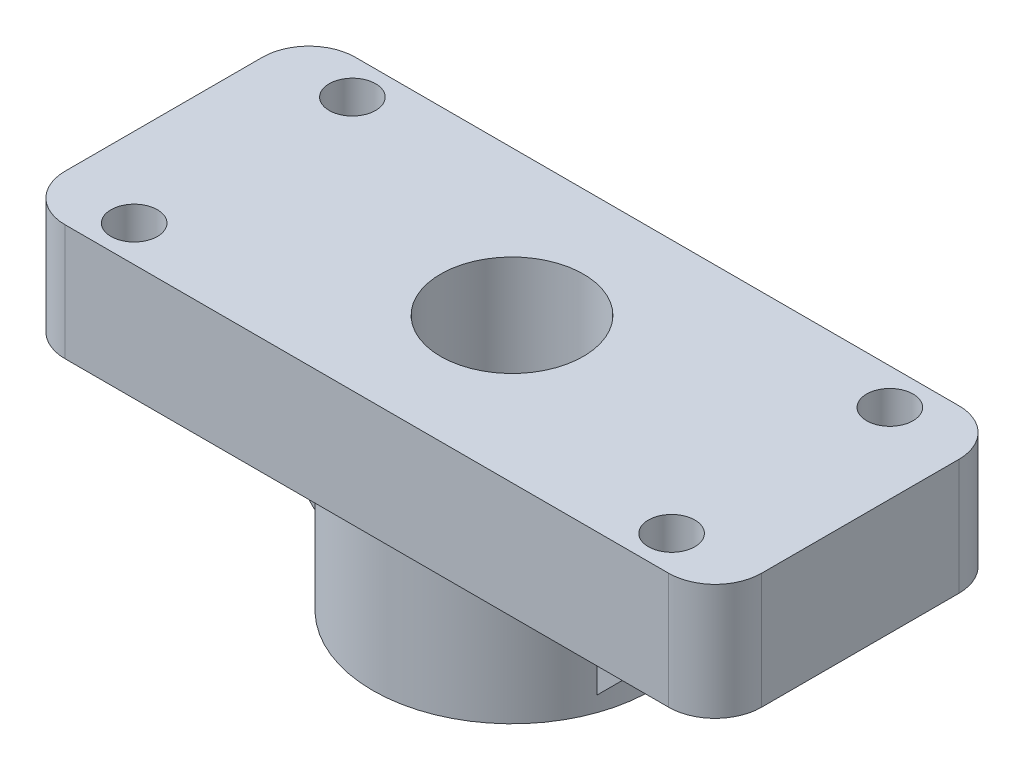
from build123d import *

# Parameters (mm, degrees)
SKETCH1_W            = 60
SKETCH1_H            = 25
BASE_DEPTH           = 10
PEN_HOLE_REACH       = 24
SKETCH5_R            = 6.15
STAB_FINS_DEPTH      = 4
STAB_FINS_DEPTH_BACK = 4
BASE_DEC_R           = 4
SKETCH8_R            = 2
CUT_EXTRUDE2_DEPTH   = 23
CHAMFER1_SIZE        = 2


with BuildPart() as part:
    # Sketch1 → Base (new body)
    with BuildSketch(Plane(origin=(0, 0, 0), x_dir=(1, 0, 0), z_dir=(0, 1, 0))):
        Rectangle(SKETCH1_W, SKETCH1_H)
    extrude(amount=BASE_DEPTH)

    # Sketch2 → Pen Catch (revolve)
    with BuildSketch(Plane.XY):
        Polygon((-6.15, 0), (-6.15, -7), (-5.4, -7), (-5.4, -12), (-12, -12), (-12, 0), align=None)
    revolve(axis=Axis((0, 0, 0), (0, -1, 0)))

    # Sketch5 → Pen Hole (cut, up to next)
    with BuildSketch(Plane(origin=(0, 10, 0), x_dir=(1, 0, 0), z_dir=(0, 1, 0)), mode=Mode.PRIVATE) as pen_hole_sk1:
        Circle(SKETCH5_R)
    pen_hole_tool1 = extrude(pen_hole_sk1.sketch, amount=-PEN_HOLE_REACH, mode=Mode.PRIVATE) & part.part
    add(pen_hole_tool1.solids().sort_by_distance((0, 10, 0))[0], mode=Mode.SUBTRACT)

    # Sketch4 → Stab Fins (add, two sides)
    with BuildSketch(Plane.XY) as stab_fins_sk:
        Polygon((-22, 0), (-10, 0), (-10, -12), align=None)
        Polygon((10, -12), (22, 0), (10, 0), align=None)
    extrude(amount=STAB_FINS_DEPTH)
    extrude(stab_fins_sk.sketch, amount=-STAB_FINS_DEPTH_BACK)

    # Base Dec
    base_dec_edges = [part.edges().sort_by_distance(p)[0] for p in [
        (-30, 5, -12.5),
        (30, 5, -12.5),
        (30, 5, 12.5),
        (-30, 5, 12.5),
    ]]
    fillet(base_dec_edges, radius=BASE_DEC_R)

    # Sketch8 → Cut-Extrude2 (cut, through all)
    with BuildSketch(Plane(origin=(0, 10, 0), x_dir=(1, 0, 0), z_dir=(0, 1, 0))):
        with Locations((23.15, 9.4)):
            Circle(SKETCH8_R)
        with Locations((23.15, -9.4)):
            Circle(SKETCH8_R)
        with Locations((-23.15, 9.4)):
            Circle(SKETCH8_R)
        with Locations((-23.15, -9.4)):
            Circle(SKETCH8_R)
    extrude(amount=-CUT_EXTRUDE2_DEPTH, mode=Mode.SUBTRACT)

    # Chamfer1
    chamfer1_edges = [part.edges().sort_by_distance(p)[0] for p in [
        (5.4, -12, 0),
    ]]
    chamfer(chamfer1_edges, length=CHAMFER1_SIZE)


solid = part.part
